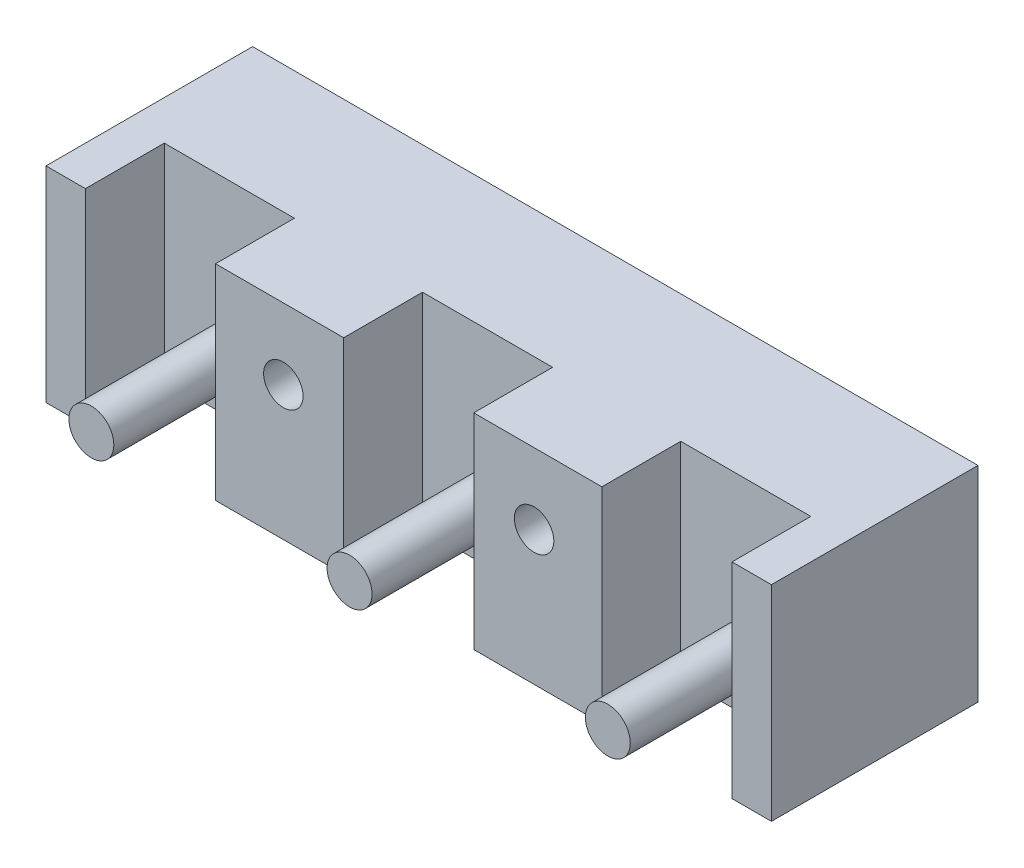
from build123d import *

# Parameters (mm, degrees)
ESBO_O1_W                = 92
ESBO_O1_H                = 26
RESSALTO_EXTRUS_O1_DEPTH = 26.2
ESBO_O2_W                = 16.5
ESBO_O2_H                = 10
CORTE_EXTRUS_O1_DEPTH    = 27
ESBO_O3_R                = 2.5
CORTE_EXTRUS_O2_DEPTH    = 27.2
ESBO_O4_R                = 2.85
RESSALTO_EXTRUS_O2_DEPTH = 17.5


with BuildPart() as part:
    # Esboço1 → Ressalto-extrusão1 (new body)
    with BuildSketch(Plane.XY):
        Rectangle(ESBO_O1_W, ESBO_O1_H)
    extrude(amount=RESSALTO_EXTRUS_O1_DEPTH)

    # Esboço2 → Corte-extrusão1 (cut, through all)
    with BuildSketch(Plane.XZ.offset(13)):
        with Locations((-32.75, 21.2)):
            Rectangle(ESBO_O2_W, ESBO_O2_H)
        with Locations((0, 21.2)):
            Rectangle(ESBO_O2_W, ESBO_O2_H)
        with Locations((32.75, 21.2)):
            Rectangle(ESBO_O2_W, ESBO_O2_H)
    extrude(amount=-CORTE_EXTRUS_O1_DEPTH, mode=Mode.SUBTRACT)

    # Esboço3 → Corte-extrusão2 (cut, through all)
    with BuildSketch(Plane(origin=(0, 0, 0), x_dir=(-1, 0, 0), z_dir=(0, 0, -1))):
        with Locations((-15.9, 4)):
            Circle(ESBO_O3_R)
        with Locations((15.9, 4)):
            Circle(ESBO_O3_R)
    extrude(amount=-CORTE_EXTRUS_O2_DEPTH, mode=Mode.SUBTRACT)

    # Esboço4 → Ressalto-extrusão2 (add)
    with BuildSketch(Plane.XY.offset(16.2)):
        with Locations((0, -5.85)):
            Circle(ESBO_O4_R)
        with Locations((32.75, -5.85)):
            Circle(ESBO_O4_R)
        with Locations((-32.75, -5.85)):
            Circle(ESBO_O4_R)
    extrude(amount=RESSALTO_EXTRUS_O2_DEPTH)


solid = part.part
